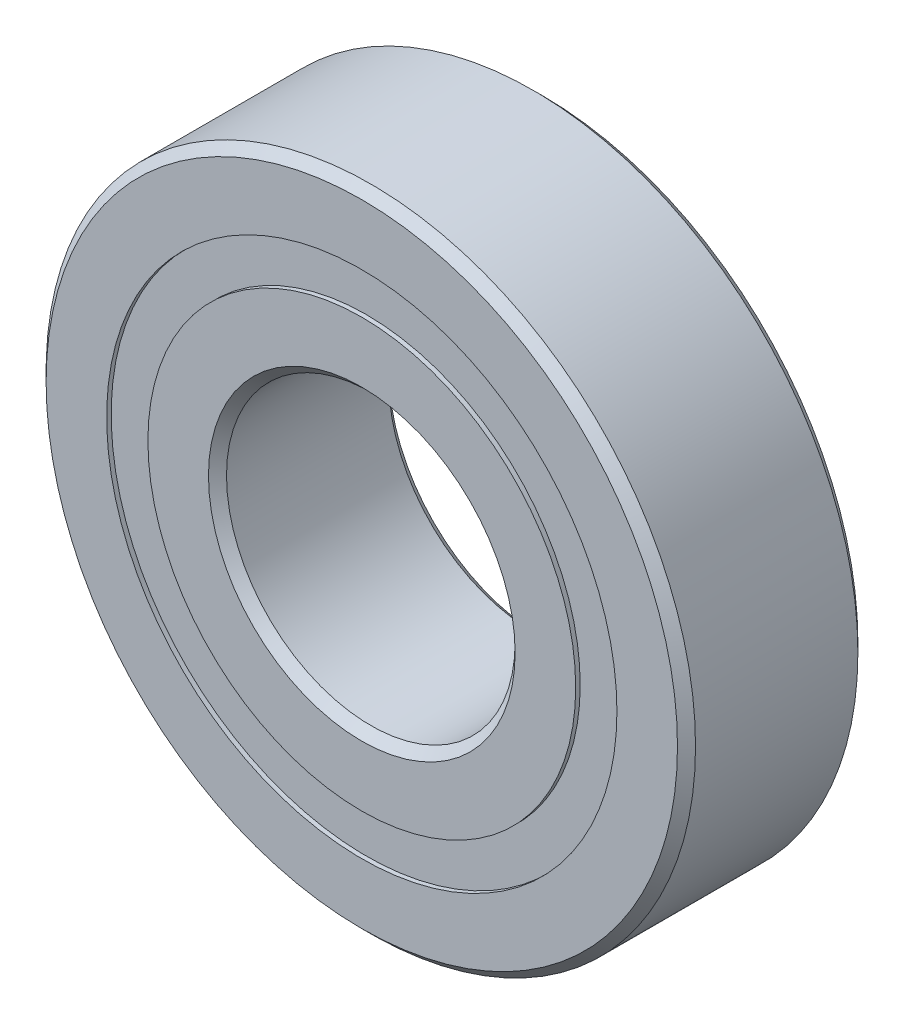
from build123d import *

# Parameters (mm, degrees)
CIRPATTERN1_COUNT = 10
SKETCH5_W         = 1.786827644
SKETCH5_H         = 1.814285714


with BuildPart() as part:
    # Sketch1 → Revolve1 (revolve)
    with BuildSketch(Plane(origin=(0, 0, 0), x_dir=(0, 0, -1), z_dir=(1, 0, 0))):
        with BuildLine():
            Line((3.571875, 14.2875), (-3.571875, 14.2875))
            Line((-3.571875, 14.2875), (-3.96875, 13.890625))
            Line((-3.96875, 13.890625), (-3.96875, 11.225892857))
            Line((-3.96875, 11.225892857), (-1.763888889, 11.225892857))
            ThreePointArc((-1.763888889, 11.225892857), (0, 12.302234856), (1.763888889, 11.225892857))
            Line((1.763888889, 11.225892857), (3.96875, 11.225892857))
            Line((3.96875, 11.225892857), (3.96875, 13.890625))
            Line((3.96875, 13.890625), (3.571875, 14.2875))
        make_face()
    revolve(axis=Axis((0, 0, 3.96875), (0, 0, -1)))


with BuildPart() as body_2:
    # Sketch3 → Revolve3 (revolve)
    with BuildSketch(Plane(origin=(0, 0, 0), x_dir=(0, 0, -1), z_dir=(1, 0, 0))):
        with BuildLine():
            Line((-3.96875, 9.411607143), (-1.763888889, 9.411607143))
            ThreePointArc((-1.763888889, 9.411607143), (0, 8.335265144), (1.763888889, 9.411607143))
            Line((1.763888889, 9.411607143), (3.96875, 9.411607143))
            Line((3.96875, 9.411607143), (3.96875, 6.746875))
            Line((3.96875, 6.746875), (3.571875, 6.35))
            Line((3.571875, 6.35), (-3.571875, 6.35))
            Line((-3.571875, 6.35), (-3.96875, 6.746875))
            Line((-3.96875, 6.746875), (-3.96875, 9.411607143))
        make_face()
    revolve(axis=Axis((0, 0, 3.96875), (0, 0, -1)))


with BuildPart() as body_3:
    # Sketch4 → Revolve4 (revolve)
    with BuildSketch(Plane(origin=(0, 0, 0), x_dir=(0, 0, -1), z_dir=(1, 0, 0))):
        with BuildLine():
            Line((-1.983484856, 10.31875), (1.983484856, 10.31875))
            ThreePointArc((1.983484856, 10.31875), (0, 12.302234856), (-1.983484856, 10.31875))
        make_face()
    revolve(axis=Axis((0, 10.31875, 1.983484856), (0, 0, -1)))


with BuildPart() as cirpattern1_1:
    # CirPattern1: pattern copy
    add(body_3.part.rotate(Axis((0, 0, 0), (0, 0, 1)), 1 * 360 / CIRPATTERN1_COUNT))


with BuildPart() as cirpattern1_2:
    # CirPattern1: pattern copy
    add(body_3.part.rotate(Axis((0, 0, 0), (0, 0, 1)), 2 * 360 / CIRPATTERN1_COUNT))


with BuildPart() as cirpattern1_3:
    # CirPattern1: pattern copy
    add(body_3.part.rotate(Axis((0, 0, 0), (0, 0, 1)), 3 * 360 / CIRPATTERN1_COUNT))


with BuildPart() as cirpattern1_4:
    # CirPattern1: pattern copy
    add(body_3.part.rotate(Axis((0, 0, 0), (0, 0, 1)), 4 * 360 / CIRPATTERN1_COUNT))


with BuildPart() as cirpattern1_5:
    # CirPattern1: pattern copy
    add(body_3.part.rotate(Axis((0, 0, 0), (0, 0, 1)), 5 * 360 / CIRPATTERN1_COUNT))


with BuildPart() as cirpattern1_6:
    # CirPattern1: pattern copy
    add(body_3.part.rotate(Axis((0, 0, 0), (0, 0, 1)), 6 * 360 / CIRPATTERN1_COUNT))


with BuildPart() as cirpattern1_7:
    # CirPattern1: pattern copy
    add(body_3.part.rotate(Axis((0, 0, 0), (0, 0, 1)), 7 * 360 / CIRPATTERN1_COUNT))


with BuildPart() as cirpattern1_8:
    # CirPattern1: pattern copy
    add(body_3.part.rotate(Axis((0, 0, 0), (0, 0, 1)), 8 * 360 / CIRPATTERN1_COUNT))


with BuildPart() as cirpattern1_9:
    # CirPattern1: pattern copy
    add(body_3.part.rotate(Axis((0, 0, 0), (0, 0, 1)), 9 * 360 / CIRPATTERN1_COUNT))


with BuildPart() as body_13:
    # Sketch5 → Revolve5 (revolve)
    with BuildSketch(Plane(origin=(0, 0, 0), x_dir=(0, 0, -1), z_dir=(1, 0, 0))):
        with Locations((-2.876898678, 10.31875)):
            Rectangle(SKETCH5_W, SKETCH5_H)
        with Locations((2.876898678, 10.31875)):
            Rectangle(SKETCH5_W, SKETCH5_H)
    revolve(axis=Axis((0, 0, 3.96875), (0, 0, -1)))


solid = Compound([part.part, body_2.part, body_3.part, cirpattern1_1.part, cirpattern1_2.part, cirpattern1_3.part, cirpattern1_4.part, cirpattern1_5.part, cirpattern1_6.part, cirpattern1_7.part, cirpattern1_8.part, cirpattern1_9.part, body_13.part])
